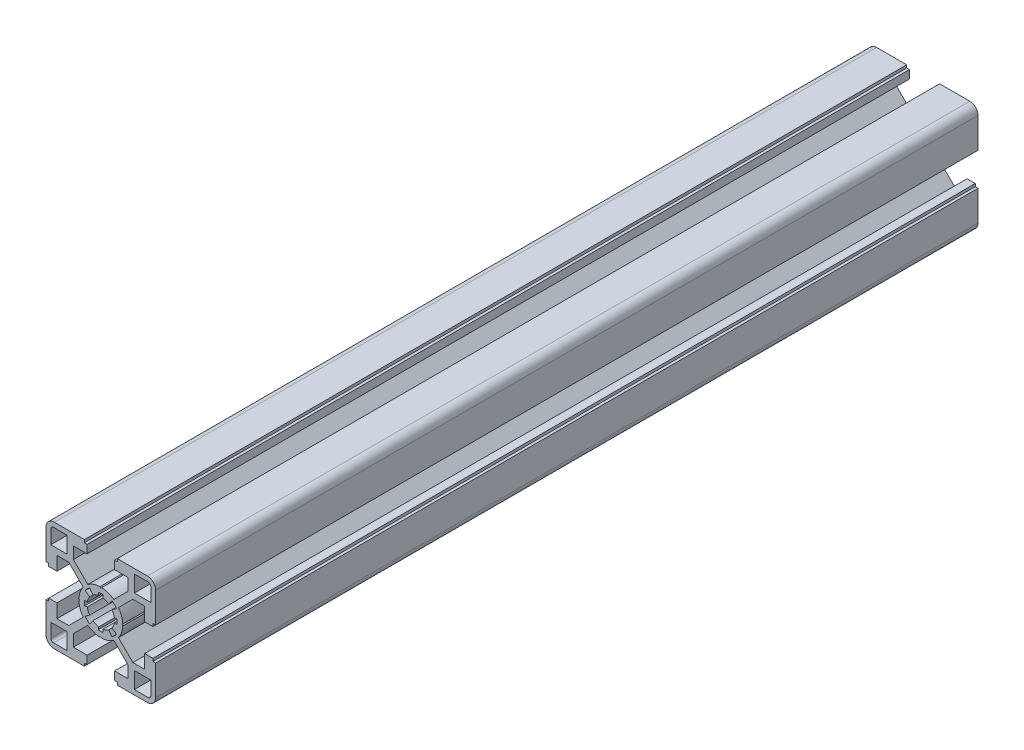
from build123d import *

# Parameters (mm, degrees)
BOSS_EXTRU_1_DEPTH = 300


with BuildPart() as part:
    # Esquisse1 → Boss.-Extru.1 (new body)
    with BuildSketch(Plane.XY.offset(100)):
        with BuildLine():
            Line((6, -19), (6, -20))
            Line((6, -20), (17, -20))
            ThreePointArc((17, -20), (19.121320344, -19.121320344), (20, -17))
            Line((20, -17), (20, -6))
            Line((20, -6), (19, -6))
            Line((19, -6), (19, -5))
            Line((19, -5), (16, -5))
            Line((16, -5), (16, -10))
            Line((16, -10), (11.697056276, -10))
            Line((11.697056276, -10), (6.44138072, -4.744324444))
            ThreePointArc((6.44138072, -4.744324444), (7.551143817, -2.642011933), (7.994130058, -0.306405969))
            Line((7.994130058, -0.306405969), (7.7, 0))
            Line((7.7, 0), (7.994130058, 0.306405971))
            ThreePointArc((7.994130058, 0.306405971), (7.551143817, 2.642011934), (6.441380719, 4.744324444))
            Line((6.441380719, 4.744324444), (11.697056275, 10))
            Line((11.697056275, 10), (16, 10))
            Line((16, 10), (16, 5))
            Line((16, 5), (19, 5))
            Line((19, 5), (19, 6))
            Line((19, 6), (20, 6))
            Line((20, 6), (20, 17))
            ThreePointArc((20, 17), (19.121320344, 19.121320344), (17, 20))
            Line((17, 20), (6, 20))
            Line((6, 20), (6, 19))
            Line((6, 19), (5, 19))
            Line((5, 19), (5, 15.999999999))
            Line((5, 15.999999999), (10.000000001, 15.999999999))
            Line((10.000000001, 15.999999999), (10.000000001, 11.697056275))
            Line((10.000000001, 11.697056275), (4.744324444, 6.441380719))
            ThreePointArc((4.744324444, 6.441380719), (2.642011933, 7.551143817), (0.306405969, 7.994130058))
            Line((0.306405969, 7.994130058), (0, 7.7))
            Line((0, 7.7), (-0.30640597, 7.994130058))
            ThreePointArc((-0.30640597, 7.994130058), (-2.642011933, 7.551143817), (-4.744324444, 6.441380719))
            Line((-4.744324444, 6.441380719), (-9.999999999, 11.697056274))
            Line((-9.999999999, 11.697056274), (-9.999999999, 15.999999999))
            Line((-9.999999999, 15.999999999), (-5, 15.999999999))
            Line((-5, 15.999999999), (-5, 19))
            Line((-5, 19), (-6, 19))
            Line((-6, 19), (-6, 20))
            Line((-6, 20), (-17, 20))
            ThreePointArc((-17, 20), (-19.121320344, 19.121320344), (-20, 17))
            Line((-20, 17), (-20, 6))
            Line((-20, 6), (-19, 6))
            Line((-19, 6), (-19, 5))
            Line((-19, 5), (-16, 5))
            Line((-16, 5), (-16, 10))
            Line((-16, 10), (-11.697056274, 10))
            Line((-11.697056274, 10), (-6.441380718, 4.744324445))
            ThreePointArc((-6.441380718, 4.744324445), (-7.551143817, 2.642011933), (-7.994130058, 0.306405969))
            Line((-7.994130058, 0.306405969), (-7.699999999, 0))
            Line((-7.699999999, 0), (-7.994130057, -0.306405971))
            ThreePointArc((-7.994130057, -0.306405971), (-7.551143816, -2.642011934), (-6.441380719, -4.744324444))
            Line((-6.441380719, -4.744324444), (-11.697056275, -10))
            Line((-11.697056275, -10), (-16, -10))
            Line((-16, -10), (-16, -5))
            Line((-16, -5), (-19, -5))
            Line((-19, -5), (-19, -6))
            Line((-19, -6), (-20, -6))
            Line((-20, -6), (-20, -17))
            ThreePointArc((-20, -17), (-19.121320344, -19.121320344), (-17, -20))
            Line((-17, -20), (-6, -20))
            Line((-6, -20), (-6, -19))
            Line((-6, -19), (-5, -19))
            Line((-5, -19), (-5, -16.000000001))
            Line((-5, -16.000000001), (-9.999999999, -16.000000001))
            Line((-9.999999999, -16.000000001), (-9.999999999, -11.697056274))
            Line((-9.999999999, -11.697056274), (-4.744324444, -6.441380719))
            ThreePointArc((-4.744324444, -6.441380719), (-2.642011933, -7.551143817), (-0.306405969, -7.994130058))
            Line((-0.306405969, -7.994130058), (0, -7.7))
            Line((0, -7.7), (0.306405971, -7.994130058))
            ThreePointArc((0.306405971, -7.994130058), (2.642011934, -7.551143817), (4.744324445, -6.441380719))
            Line((4.744324445, -6.441380719), (10.000000001, -11.697056274))
            Line((10.000000001, -11.697056274), (10.000000001, -16.000000001))
            Line((10.000000001, -16.000000001), (5, -16.000000001))
            Line((5, -16.000000001), (5, -19))
            Line((5, -19), (6, -19))
        make_face()
        with BuildLine():
            Line((18.25, 12.25), (12.25, 12.25))
            Line((12.25, 12.25), (12.25, 18.25))
            Line((12.25, 18.25), (17.25, 18.25))
            ThreePointArc((17.25, 18.25), (17.957106781, 17.957106781), (18.25, 17.25))
            Line((18.25, 17.25), (18.25, 12.25))
        make_face(mode=Mode.SUBTRACT)
        with BuildLine():
            Line((-18.25, -12.25), (-12.25, -12.25))
            Line((-12.25, -12.25), (-12.25, -18.25))
            Line((-12.25, -18.25), (-17.25, -18.25))
            ThreePointArc((-17.25, -18.25), (-17.957106781, -17.957106781), (-18.25, -17.25))
            Line((-18.25, -17.25), (-18.25, -12.25))
        make_face(mode=Mode.SUBTRACT)
        with BuildLine():
            Line((-12.25, 18.25), (-12.25, 12.25))
            Line((-12.25, 12.25), (-18.25, 12.25))
            Line((-18.25, 12.25), (-18.25, 17.25))
            ThreePointArc((-18.25, 17.25), (-17.957106781, 17.957106781), (-17.25, 18.25))
            Line((-17.25, 18.25), (-12.25, 18.25))
        make_face(mode=Mode.SUBTRACT)
        with BuildLine():
            Line((12.25, -18.25), (12.25, -12.25))
            Line((12.25, -12.25), (18.25, -12.25))
            Line((18.25, -12.25), (18.25, -17.25))
            ThreePointArc((18.25, -17.25), (17.957106781, -17.957106781), (17.25, -18.25))
            Line((17.25, -18.25), (12.25, -18.25))
        make_face(mode=Mode.SUBTRACT)
        with BuildLine():
            Line((-5.705709703, -4.055228326), (-4.075506937, -2.896591666))
            ThreePointArc((-4.075506937, -2.896591666), (-4.635549589, -1.873947727), (-4.943520622, -0.749402378))
            Line((-4.943520622, -0.749402378), (-5.932224738, -0.899282852))
            ThreePointArc((-5.932224738, -0.899282852), (-6, 0), (-5.932224738, 0.899282853))
            Line((-5.932224738, 0.899282853), (-4.943520622, 0.749402379))
            ThreePointArc((-4.943520622, 0.749402379), (-4.635549588, 1.873947727), (-4.075506937, 2.896591666))
            Line((-4.075506937, 2.896591666), (-5.705709704, 4.055228326))
            ThreePointArc((-5.705709704, 4.055228326), (-4.953610357, 4.945881563), (-4.064132573, 5.699370705))
            Line((-4.064132573, 5.699370705), (-2.902951842, 4.070979081))
            ThreePointArc((-2.902951842, 4.070979081), (-1.877566249, 4.634085136), (-0.749402377, 4.943520623))
            Line((-0.749402377, 4.943520623), (-0.899282852, 5.932224739))
            ThreePointArc((-0.899282852, 5.932224739), (0, 6), (0.899282852, 5.932224739))
            Line((0.899282852, 5.932224739), (0.749402377, 4.943520623))
            ThreePointArc((0.749402377, 4.943520623), (1.87756625, 4.634085136), (2.902951843, 4.07097908))
            Line((2.902951843, 4.07097908), (4.064132575, 5.699370704))
            ThreePointArc((4.064132575, 5.699370704), (4.953610358, 4.945881562), (5.705709704, 4.055228326))
            Line((5.705709704, 4.055228326), (4.075506937, 2.896591666))
            ThreePointArc((4.075506937, 2.896591666), (4.635549589, 1.873947727), (4.943520623, 0.749402378))
            Line((4.943520623, 0.749402378), (5.932224739, 0.899282853))
            ThreePointArc((5.932224739, 0.899282853), (6, 0), (5.932224739, -0.899282853))
            Line((5.932224739, -0.899282853), (4.943520623, -0.749402379))
            ThreePointArc((4.943520623, -0.749402379), (4.635549589, -1.873947727), (4.075506938, -2.896591666))
            Line((4.075506938, -2.896591666), (5.705709704, -4.055228326))
            ThreePointArc((5.705709704, -4.055228326), (4.953610357, -4.945881563), (4.064132573, -5.699370705))
            Line((4.064132573, -5.699370705), (2.902951842, -4.070979081))
            ThreePointArc((2.902951842, -4.070979081), (1.87756625, -4.634085136), (0.749402378, -4.943520623))
            Line((0.749402378, -4.943520623), (0.899282852, -5.932224739))
            ThreePointArc((0.899282852, -5.932224739), (1e-09, -6), (-0.899282851, -5.932224739))
            Line((-0.899282851, -5.932224739), (-0.749402377, -4.943520623))
            ThreePointArc((-0.749402377, -4.943520623), (-1.87756625, -4.634085136), (-2.902951843, -4.07097908))
            Line((-2.902951843, -4.07097908), (-4.064132574, -5.699370704))
            ThreePointArc((-4.064132574, -5.699370704), (-4.953610357, -4.945881562), (-5.705709703, -4.055228326))
        make_face(mode=Mode.SUBTRACT)
    extrude(amount=-BOSS_EXTRU_1_DEPTH)


solid = part.part
